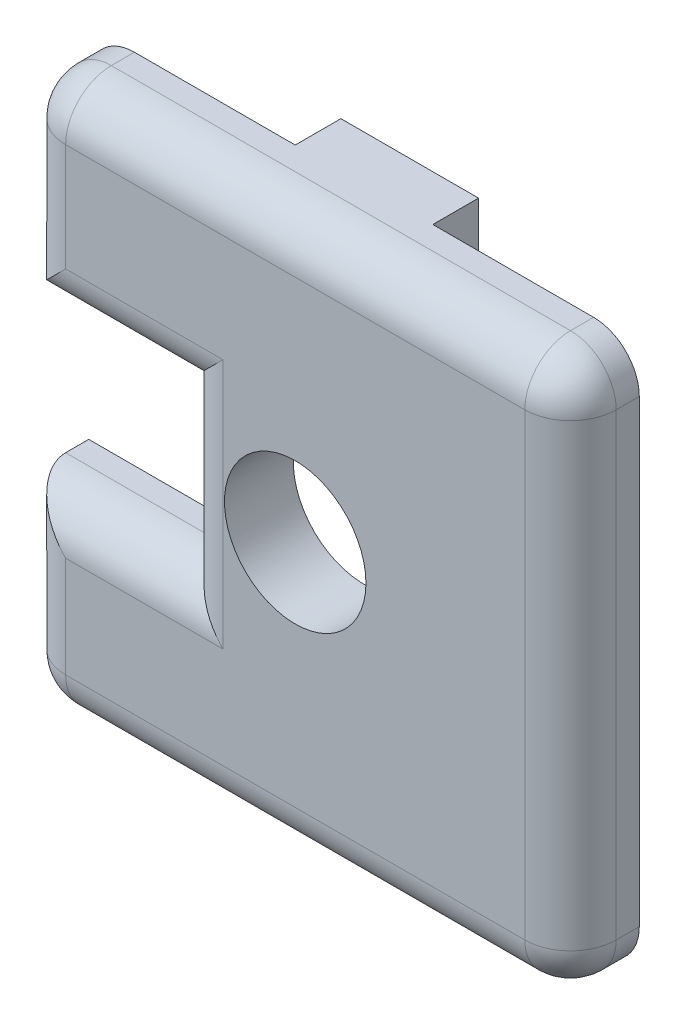
from build123d import *

# Parameters (mm, degrees)
BOSS_EXTRUDE1_DEPTH = 3.175
FILLET1_R           = 2.1082
CUT_EXTRUDE1_REACH  = 5.175
SKETCH2_R           = 3.2639
SKETCH3_W           = 6.35
SKETCH3_H           = 2.1082
BOSS_EXTRUDE2_DEPTH = 2.1082


with BuildPart() as part:
    # Sketch1 → Boss-Extrude1 (new body)
    with BuildSketch(Plane.XY):
        Polygon((-12.7, 12.7), (12.7, 12.7), (12.7, -12.7), (-12.7, -12.7), (-12.7, -3.822069256), (-5.441576375, -3.822069256), (-5.441576375, 3.520801512), (-12.7, 3.520801512), align=None)
    extrude(amount=BOSS_EXTRUDE1_DEPTH)

    # Fillet1
    fillet1_edges = [part.edges().sort_by_distance(p)[0] for p in [
        (-5.441576375, -0.150633872, 3.175),
        (-9.070788187, -3.822069256, 3.175),
        (-12.7, 12.7, 1.5875),
        (12.7, 12.7, 1.5875),
        (12.7, -12.7, 1.5875),
        (-12.7, -12.7, 1.5875),
        (-12.7, -8.261034628, 3.175),
        (0, -12.7, 3.175),
        (12.7, 0, 3.175),
        (0, 12.7, 3.175),
        (-12.7, 8.110400756, 3.175),
        (-9.070788187, 3.520801512, 3.175),
    ]]
    fillet(fillet1_edges, radius=FILLET1_R)

    # Sketch2 → Cut-Extrude1 (cut, up to next)
    with BuildSketch(Plane.XY.offset(3.175), mode=Mode.PRIVATE) as cut_extrude1_sk1:
        Circle(SKETCH2_R)
    cut_extrude1_tool1 = extrude(cut_extrude1_sk1.sketch, amount=-CUT_EXTRUDE1_REACH, mode=Mode.PRIVATE) & part.part
    add(cut_extrude1_tool1.solids().sort_by_distance((0, 0, 3.175))[0], mode=Mode.SUBTRACT)

    # Sketch3 → Boss-Extrude2 (add)
    with BuildSketch(Plane(origin=(0, 0, 0), x_dir=(-1, 0, 0), z_dir=(0, 0, -1))):
        with Locations((0, 11.6459)):
            Rectangle(SKETCH3_W, SKETCH3_H)
    extrude(amount=BOSS_EXTRUDE2_DEPTH)


solid = part.part
